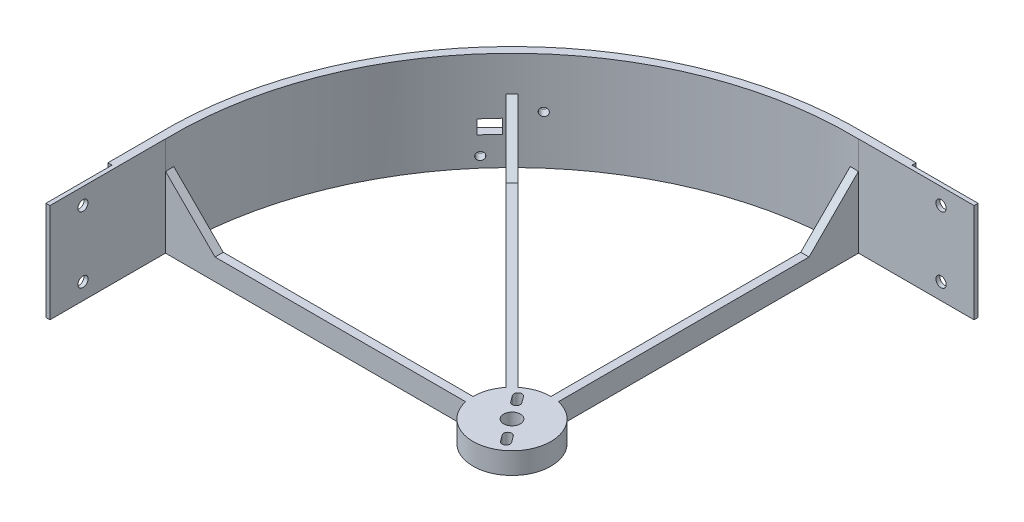
from build123d import *

# Parameters (mm, degrees)
SKETCH1_R            = 15
BOSS_EXTRUDE2_DEPTH  = 8.255
BOSS_EXTRUDE3_DEPTH  = 8.255
BOSS_EXTRUDE4_DEPTH  = 38.1
SKETCH5_R            = 3.249999977
CUT_EXTRUDE3_DEPTH   = 63.5
BOSS_EXTRUDE13_DEPTH = 3.175
BOSS_EXTRUDE14_DEPTH = 3.175
BOSS_EXTRUDE15_DEPTH = 3.175
CUT_EXTRUDE6_DEPTH   = 9.255
SKETCH20_W           = 38.1
SKETCH20_H           = 44.45
BOSS_EXTRUDE16_DEPTH = 1.524
SKETCH21_W           = 38.1
SKETCH21_H           = 44.45
BOSS_EXTRUDE17_DEPTH = 1.524
SKETCH23_R           = 1.9431
CUT_EXTRUDE7_DEPTH   = 2.54
SKETCH24_R           = 1.98501
CUT_EXTRUDE8_DEPTH   = 2.54
SKETCH25_W           = 19.05
SKETCH25_H           = 38.1
BOSS_EXTRUDE18_DEPTH = 1.587961
SKETCH26_W           = 19.05
SKETCH26_H           = 38.1
BOSS_EXTRUDE19_DEPTH = 1.587961
BOSS_EXTRUDE20_START = -0.60614
SKETCH27_W           = 25.4
SKETCH27_H           = 22.811309973
BOSS_EXTRUDE20_DEPTH = 0.60614
CUT_EXTRUDE9_REACH   = 202.702
SKETCH29_R           = 1.524
CUT_EXTRUDE10_REACH  = 202.702
SKETCH30_W           = 6.954293398
SKETCH30_H           = 5.349239075


with BuildPart() as part:
    # Sketch1 → Boss-Extrude2 (new body)
    with BuildSketch(Plane(origin=(0, 0, 0), x_dir=(1, 0, 0), z_dir=(0, 1, 0))):
        Circle(SKETCH1_R)
    extrude(amount=BOSS_EXTRUDE2_DEPTH)

    # Sketch1_6 → Boss-Extrude3 (add)
    with BuildSketch(Plane(origin=(0, 0, 0), x_dir=(1, 0, 0), z_dir=(0, 1, 0))):
        with BuildLine():
            ThreePointArc((3.175, 130.136274728), (1.587618078, 130.165318322), (0, 130.175))
            Line((0, 130.175), (0, 15))
            ThreePointArc((0, 15), (1.596569562, 14.914790164), (3.175, 14.660128751))
            Line((3.175, 14.660128751), (3.175, 130.136274728))
        make_face()
        with BuildLine():
            Line((-9.42450178, 11.66956581), (-90.918248264, 93.163312294))
            ThreePointArc((-90.918248264, 93.163312294), (-92.047625241, 92.047625241), (-93.163312294, 90.918248264))
            Line((-93.163312294, 90.918248264), (-11.66956581, 9.42450178))
            ThreePointArc((-11.66956581, 9.42450178), (-10.606601718, 10.606601718), (-9.42450178, 11.66956581))
        make_face()
        with BuildLine():
            Line((-15, 0), (-130.175, 0))
            ThreePointArc((-130.175, 0), (-130.165318322, -1.587618078), (-130.136274728, -3.175))
            Line((-130.136274728, -3.175), (-14.660128751, -3.175))
            ThreePointArc((-14.660128751, -3.175), (-14.914790164, -1.596569562), (-15, 0))
        make_face()
    extrude(amount=BOSS_EXTRUDE3_DEPTH)

    # Sketch1_7 → Boss-Extrude4 (add)
    with BuildSketch(Plane(origin=(0, 0, 0), x_dir=(1, 0, 0), z_dir=(0, 1, 0))):
        with BuildLine():
            Line((3.175, 130.136274728), (3.175, 133.312197023))
            ThreePointArc((3.175, 133.312197023), (-94.292689271, 94.292689271), (-133.312197023, -3.175))
            Line((-133.312197023, -3.175), (-130.136274728, -3.175))
            ThreePointArc((-130.136274728, -3.175), (-92.047625241, 92.047625241), (3.175, 130.136274728))
        make_face()
    extrude(amount=BOSS_EXTRUDE4_DEPTH)

    # Sketch5 → Cut-Extrude3 (cut)
    with BuildSketch(Plane(origin=(0, 8.255, 0), x_dir=(1, 0, 0), z_dir=(0, 1, 0))):
        Circle(SKETCH5_R)
    extrude(amount=-CUT_EXTRUDE3_DEPTH, mode=Mode.SUBTRACT)

    # Sketch14 → Boss-Extrude13 (add)
    with BuildSketch(Plane(origin=(0, 0, 0), x_dir=(-1, 0, 0), z_dir=(0, 0, -1))):
        Polygon((130.175, 8.255), (111.125, 8.255), (130.175, 27.305), align=None)
    extrude(amount=-BOSS_EXTRUDE13_DEPTH)

    # Sketch15 → Boss-Extrude14 (add)
    with BuildSketch(Plane.ZY):
        Polygon((-130.175, 8.255), (-130.175, 27.305), (-111.125, 8.255), align=None)
    extrude(amount=-BOSS_EXTRUDE14_DEPTH)

    # Sketch16 → Boss-Extrude15 (add)
    with BuildSketch(Plane(origin=(1.122532015, 0, -1.122532015), x_dir=(-0.707106781, 0, -0.707106781), z_dir=(0.707106781, 0, -0.707106781))):
        Polygon((133.340319762, 8.255), (111.115319762, 8.255), (133.340319762, 27.305), align=None)
    extrude(amount=-BOSS_EXTRUDE15_DEPTH)

    # Sketch17 → Cut-Extrude6 (cut, through all)
    with BuildSketch(Plane(origin=(0, 8.255, 0), x_dir=(1, 0, 0), z_dir=(0, 1, 0))):
        with BuildLine():
            Line((-5.908712478, 5.423058993), (-7.721732332, 7.873214705))
            ThreePointArc((-7.721732332, 7.873214705), (-7.403164404, 10.004802487), (-5.271576621, 9.686234559))
            Line((-5.271576621, 9.686234559), (-3.458556767, 7.236078848))
            ThreePointArc((-3.458556767, 7.236078848), (-3.777124696, 5.104491065), (-5.908712478, 5.423058993))
        make_face()
        with BuildLine():
            Line((3.458556767, -7.236078848), (5.271576621, -9.686234559))
            ThreePointArc((5.271576621, -9.686234559), (7.403164404, -10.004802487), (7.721732332, -7.873214705))
            Line((7.721732332, -7.873214705), (5.908712478, -5.423058993))
            ThreePointArc((5.908712478, -5.423058993), (3.777124696, -5.104491065), (3.458556767, -7.236078848))
        make_face()
    extrude(amount=-CUT_EXTRUDE6_DEPTH, mode=Mode.SUBTRACT)

    # Sketch20 → Boss-Extrude16 (add)
    with BuildSketch(Plane(origin=(0, 0, -131.724235875), x_dir=(0, -1, 0), z_dir=(0, 0, -1))):
        with Locations((-19.05, -25.4)):
            Rectangle(SKETCH20_W, SKETCH20_H)
    extrude(amount=-BOSS_EXTRUDE16_DEPTH)

    # Sketch21 → Boss-Extrude17 (add)
    with BuildSketch(Plane(origin=(-131.724235875, 0, 0), x_dir=(0, -1, 0), z_dir=(-1, 0, 0))):
        with Locations((-19.05, 25.4)):
            Rectangle(SKETCH21_W, SKETCH21_H)
    extrude(amount=-BOSS_EXTRUDE17_DEPTH)

    # Sketch23 → Cut-Extrude7 (cut)
    with BuildSketch(Plane.ZY.offset(131.724235875)):
        with Locations((34.925, 31.75)):
            Circle(SKETCH23_R)
        with Locations((34.925, 6.35)):
            Circle(SKETCH23_R)
    extrude(amount=-CUT_EXTRUDE7_DEPTH, mode=Mode.SUBTRACT)

    # Sketch24 → Cut-Extrude8 (cut)
    with BuildSketch(Plane(origin=(0, 0, -131.724235875), x_dir=(-1, 0, 0), z_dir=(0, 0, -1))):
        with Locations((-34.925, 31.75)):
            Circle(SKETCH24_R)
        with Locations((-34.925, 6.35)):
            Circle(SKETCH24_R)
    extrude(amount=-CUT_EXTRUDE8_DEPTH, mode=Mode.SUBTRACT)

    # Sketch25 → Boss-Extrude18 (add)
    with BuildSketch(Plane.ZY.offset(131.724235875)):
        with Locations((12.7, 19.05)):
            Rectangle(SKETCH25_W, SKETCH25_H)
    extrude(amount=BOSS_EXTRUDE18_DEPTH)

    # Sketch26 → Boss-Extrude19 (add)
    with BuildSketch(Plane(origin=(0, 0, -131.724235875), x_dir=(-1, 0, 0), z_dir=(0, 0, -1))):
        with Locations((-12.7, 19.05)):
            Rectangle(SKETCH26_W, SKETCH26_H)
    extrude(amount=BOSS_EXTRUDE19_DEPTH)

    # Sketch27 → Boss-Extrude20 (add)
    with BuildSketch(Plane(origin=(-94.292689271, 0, -94.292689271), x_dir=(-0.707106781, 0, 0.707106781), z_dir=(-0.707106781, 0, -0.707106781)).offset(BOSS_EXTRUDE20_START)):
        with Locations((0, 11.405654987)):
            Rectangle(SKETCH27_W, SKETCH27_H)
    extrude(amount=BOSS_EXTRUDE20_DEPTH)

    # Sketch29 → Cut-Extrude9 (cut, up to next)
    with BuildSketch(Plane(origin=(-94.292689271, 0, -94.292689271), x_dir=(-0.707106781, 0, 0.707106781), z_dir=(-0.707106781, 0, -0.707106781)), mode=Mode.PRIVATE) as cut_extrude9_sk1:
        with Locations((8.636, 4.064)):
            Circle(SKETCH29_R)
    cut_extrude9_tool1 = extrude(cut_extrude9_sk1.sketch, amount=-CUT_EXTRUDE9_REACH, mode=Mode.PRIVATE) & part.part
    add(cut_extrude9_tool1.solids().sort_by_distance((-100.399263, 4.064, -88.186115))[0], mode=Mode.SUBTRACT)
    # Sketch29 → Cut-Extrude9 (cut, up to next)
    with BuildSketch(Plane(origin=(-94.292689271, 0, -94.292689271), x_dir=(-0.707106781, 0, 0.707106781), z_dir=(-0.707106781, 0, -0.707106781)), mode=Mode.PRIVATE) as cut_extrude9_sk2:
        with Locations((-8.636, 18.747309973)):
            Circle(SKETCH29_R)
    cut_extrude9_tool2 = extrude(cut_extrude9_sk2.sketch, amount=-CUT_EXTRUDE9_REACH, mode=Mode.PRIVATE) & part.part
    add(cut_extrude9_tool2.solids().sort_by_distance((-88.186115, 18.74731, -100.399263))[0], mode=Mode.SUBTRACT)

    # Sketch30 → Cut-Extrude10 (cut, up to next)
    with BuildSketch(Plane(origin=(-94.292689271, 0, -94.292689271), x_dir=(-0.707106781, 0, 0.707106781), z_dir=(-0.707106781, 0, -0.707106781)), mode=Mode.PRIVATE) as cut_extrude10_sk1:
        with Locations((6.047853301, 13.786690436)):
            Rectangle(SKETCH30_W, SKETCH30_H)
    cut_extrude10_tool1 = extrude(cut_extrude10_sk1.sketch, amount=-CUT_EXTRUDE10_REACH, mode=Mode.PRIVATE) & part.part
    add(cut_extrude10_tool1.solids().sort_by_distance((-98.569167, 13.78669, -90.016211))[0], mode=Mode.SUBTRACT)


solid = part.part
